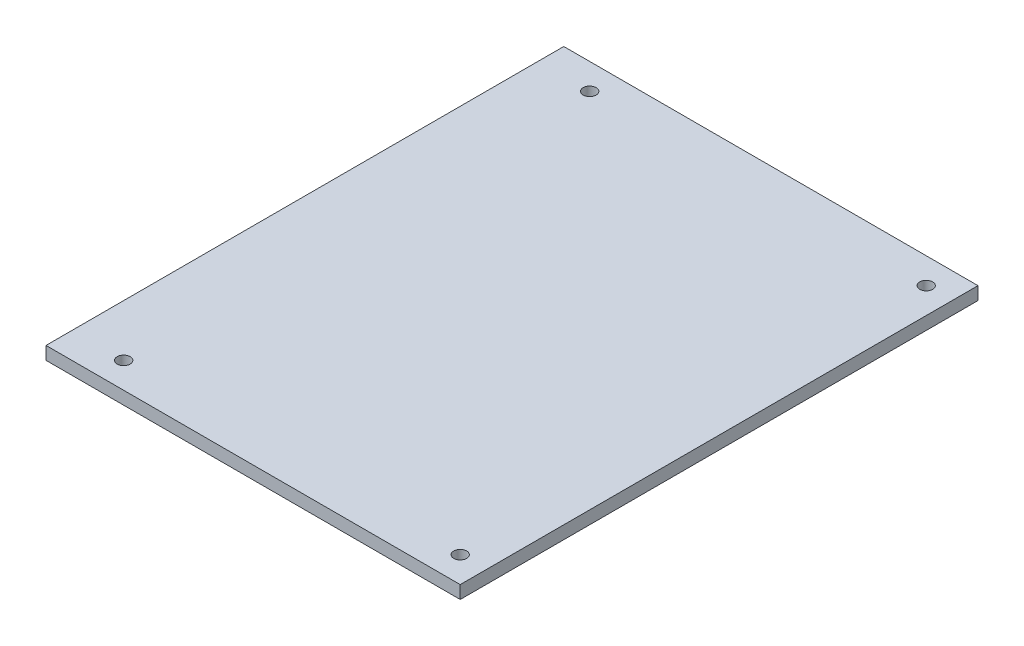
from build123d import *

# Parameters (mm, degrees)
SKETCH1_W           = 203.2
SKETCH1_H           = 254
BOSS_EXTRUDE1_DEPTH = 6.35
SKETCH2_R           = 3.175
CUT_EXTRUDE1_DEPTH  = 25.4


with BuildPart() as part:
    # Sketch1 → Boss-Extrude1 (new body)
    with BuildSketch(Plane(origin=(0, 0, 0), x_dir=(1, 0, 0), z_dir=(0, 1, 0))):
        with Locations((101.6, 127)):
            Rectangle(SKETCH1_W, SKETCH1_H)
    extrude(amount=BOSS_EXTRUDE1_DEPTH)

    # Sketch2 → Cut-Extrude1 (cut)
    with BuildSketch(Plane(origin=(0, 6.35, 0), x_dir=(1, 0, 0), z_dir=(0, 1, 0))):
        with Locations((25.4, 241.3)):
            Circle(SKETCH2_R)
        with Locations((25.4, 12.7)):
            Circle(SKETCH2_R)
        with Locations((190.5, 12.7)):
            Circle(SKETCH2_R)
        with Locations((190.5, 241.3)):
            Circle(SKETCH2_R)
    extrude(amount=-CUT_EXTRUDE1_DEPTH, mode=Mode.SUBTRACT)


solid = part.part
